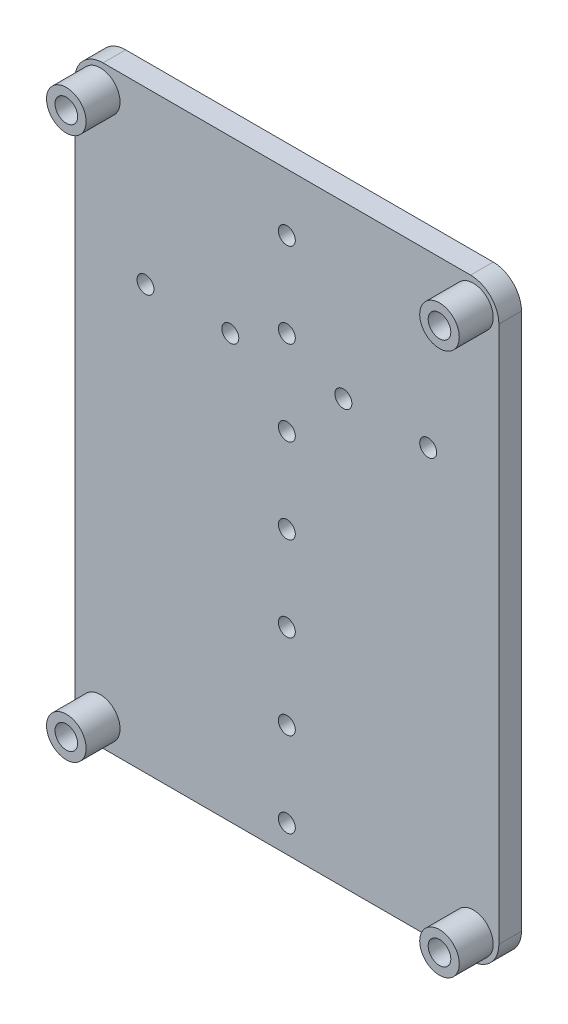
from build123d import *

# Parameters (mm, degrees)
SKETCH1_W           = 75
SKETCH1_H           = 105
SKETCH1_R           = 1.5
SKETCH1_R_2         = 2
BOSS_EXTRUDE1_DEPTH = 4
SKETCH2_R           = 3.5
SKETCH2_R_2         = 2
BOSS_EXTRUDE2_DEPTH = 6
FILLET1_R           = 5


with BuildPart() as part:
    # Sketch1 → Boss-Extrude1 (new body)
    with BuildSketch(Plane(origin=(0, 0, 116.694714263), x_dir=(-1, 0, 0), z_dir=(0, 0, -1))):
        with Locations((-134.526557277, 112.311918208)):
            Rectangle(SKETCH1_W, SKETCH1_H)
        with Locations((-134.526557277, 154.637085275)):
            Circle(SKETCH1_R, mode=Mode.SUBTRACT)
        with Locations((-134.526557277, 139.637085275)):
            Circle(SKETCH1_R, mode=Mode.SUBTRACT)
        with Locations((-144.526557277, 134.637085275)):
            Circle(SKETCH1_R, mode=Mode.SUBTRACT)
        with Locations((-159.526557277, 134.637085275)):
            Circle(SKETCH1_R, mode=Mode.SUBTRACT)
        with Locations((-124.526557277, 134.637085275)):
            Circle(SKETCH1_R, mode=Mode.SUBTRACT)
        with Locations((-109.526557277, 134.637085275)):
            Circle(SKETCH1_R, mode=Mode.SUBTRACT)
        with Locations((-134.526557277, 124.637085275)):
            Circle(SKETCH1_R, mode=Mode.SUBTRACT)
        with Locations((-134.526557277, 109.637085275)):
            Circle(SKETCH1_R, mode=Mode.SUBTRACT)
        with Locations((-134.526557277, 94.637085275)):
            Circle(SKETCH1_R, mode=Mode.SUBTRACT)
        with Locations((-134.526557277, 79.637085275)):
            Circle(SKETCH1_R, mode=Mode.SUBTRACT)
        with Locations((-134.526557277, 64.637085275)):
            Circle(SKETCH1_R, mode=Mode.SUBTRACT)
        with Locations((-167.526557277, 64.311918208)):
            Circle(SKETCH1_R_2, mode=Mode.SUBTRACT)
        with Locations((-101.526557277, 64.311918208)):
            Circle(SKETCH1_R_2, mode=Mode.SUBTRACT)
        with Locations((-101.526557277, 160.311918208)):
            Circle(SKETCH1_R_2, mode=Mode.SUBTRACT)
        with Locations((-167.526557277, 160.311918208)):
            Circle(SKETCH1_R_2, mode=Mode.SUBTRACT)
    extrude(amount=BOSS_EXTRUDE1_DEPTH)

    # Sketch2 → Boss-Extrude2 (add)
    with BuildSketch(Plane.XY.offset(116.694714263)):
        with Locations((101.526557277, 160.311918208)):
            Circle(SKETCH2_R)
        with Locations((101.526557277, 160.311918208)):
            Circle(SKETCH2_R_2, mode=Mode.SUBTRACT)
        with Locations((167.526557277, 160.311918208)):
            Circle(SKETCH2_R)
        with Locations((167.526557277, 160.311918208)):
            Circle(SKETCH2_R_2, mode=Mode.SUBTRACT)
        with Locations((101.526557277, 64.311918208)):
            Circle(SKETCH2_R)
        with Locations((101.526557277, 64.311918208)):
            Circle(SKETCH2_R_2, mode=Mode.SUBTRACT)
        with Locations((167.526557277, 64.311918208)):
            Circle(SKETCH2_R)
        with Locations((167.526557277, 64.311918208)):
            Circle(SKETCH2_R_2, mode=Mode.SUBTRACT)
    extrude(amount=BOSS_EXTRUDE2_DEPTH)

    # Fillet1
    fillet1_edges = [part.edges().sort_by_distance(p)[0] for p in [
        (172.026557277, 164.811918208, 114.694714263),
        (97.026557277, 164.811918208, 114.694714263),
        (97.026557277, 59.811918208, 114.694714263),
        (172.026557277, 59.811918208, 114.694714263),
    ]]
    fillet(fillet1_edges, radius=FILLET1_R)


solid = part.part
